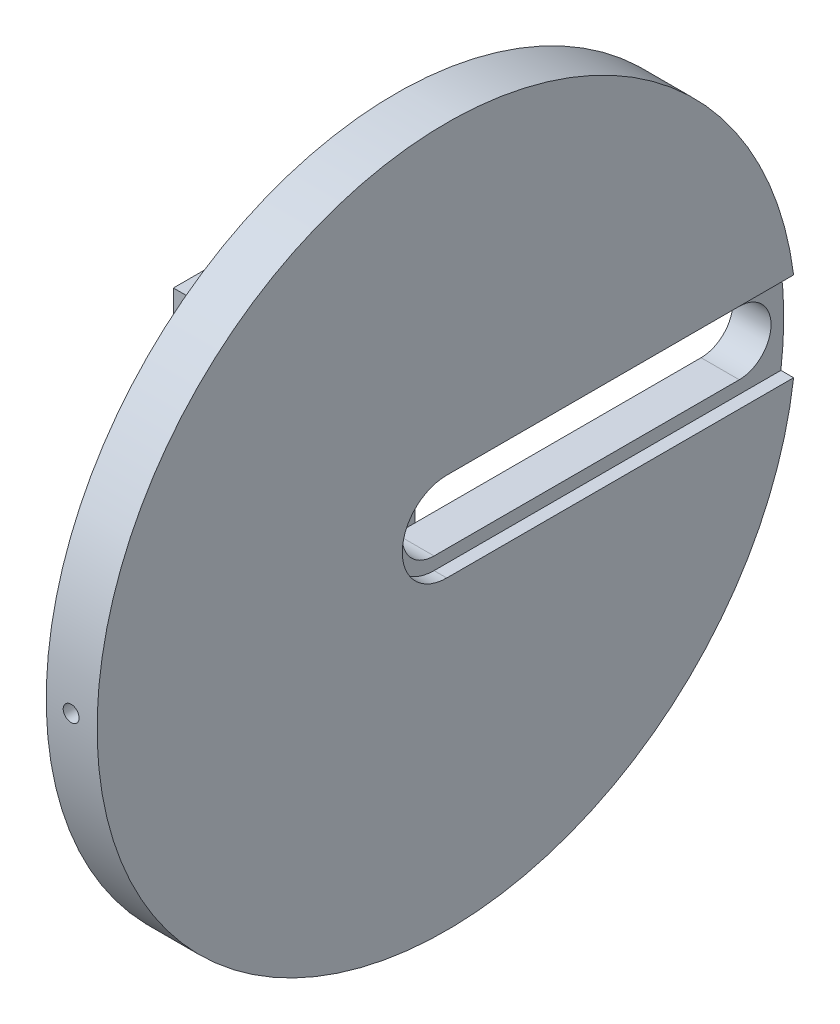
from build123d import *

# Parameters (mm, degrees)
SKETCH_1_R             = 7.5
EXTRUDE_1_DEPTH        = 10
SKETCH_5_W             = 30
SKETCH_5_H             = 52
EXTRUDE_2_DEPTH        = 8
SKETCH_6_W             = 30
SKETCH_6_H             = 8
EXTRUDE_3_DEPTH        = 12
SKETCH_7_R             = 55
EXTRUDE_4_DEPTH        = 8
CUT_EXTRUDE_4_REACH    = 40
CUT_EXTRUDE_6_DEPTH    = 2
CUT_EXTRUDE_7_REACH    = 40
SKETCH_12_R            = 9
HOLE_WIZARD_M3_1_D     = 2.5
HOLE_WIZARD_M3_1_DEPTH = 5
HOLE_WIZARD_M3_1_TIP   = 0.751075774


with BuildPart() as part:
    # 草图1 → 凸台-拉伸1 (new body)
    with BuildSketch(Plane(origin=(0, 0, 0), x_dir=(0, 0, -1), z_dir=(1, 0, 0))):
        Circle(SKETCH_1_R)
    extrude(amount=EXTRUDE_1_DEPTH)

    # 草图5 → 凸台-拉伸2 (add)
    with BuildSketch(Plane(origin=(10, 0, 0), x_dir=(0, 0, -1), z_dir=(1, 0, 0))):
        Rectangle(SKETCH_5_W, SKETCH_5_H)
    extrude(amount=EXTRUDE_2_DEPTH)

    # 草图6 → 凸台-拉伸3 (add)
    with BuildSketch(Plane(origin=(18, 0, 0), x_dir=(0, 0, -1), z_dir=(1, 0, 0))):
        with Locations((0, 22)):
            Rectangle(SKETCH_6_W, SKETCH_6_H)
        with Locations((0, -22)):
            Rectangle(SKETCH_6_W, SKETCH_6_H)
    extrude(amount=EXTRUDE_3_DEPTH)

    # 草图7 → 凸台-拉伸4 (add)
    with BuildSketch(Plane(origin=(30, 0, 0), x_dir=(0, 0, -1), z_dir=(1, 0, 0))):
        Circle(SKETCH_7_R)
    extrude(amount=EXTRUDE_4_DEPTH)

    # 草图8 → 切除-拉伸4 (cut, up to next)
    with BuildSketch(Plane(origin=(38, 0, 0), x_dir=(0, 0, -1), z_dir=(1, 0, 0)), mode=Mode.PRIVATE) as cut_extrude_4_sk1:
        with BuildLine():
            Line((0, 5), (48, 5))
            ThreePointArc((48, 5), (53, 0), (48, -5))
            Line((48, -5), (0, -5))
            ThreePointArc((0, -5), (-5, 0), (0, 5))
        make_face()
    cut_extrude_4_tool1 = extrude(cut_extrude_4_sk1.sketch, amount=-CUT_EXTRUDE_4_REACH, mode=Mode.PRIVATE) & part.part
    add(cut_extrude_4_tool1.solids().sort_by_distance((38, 0, -24))[0], mode=Mode.SUBTRACT)

    # 草图11 → 切除-拉伸6 (cut)
    with BuildSketch(Plane(origin=(38, 0, 0), x_dir=(0, 0, -1), z_dir=(1, 0, 0))):
        with BuildLine():
            Line((0, 7), (54.552726788, 7))
            ThreePointArc((54.552726788, 7), (55, 0), (54.552726788, -7))
            Line((54.552726788, -7), (0, -7))
            ThreePointArc((0, -7), (-7, 0), (0, 7))
        make_face()
    extrude(amount=-CUT_EXTRUDE_6_DEPTH, mode=Mode.SUBTRACT)

    # 草图12 → 切除-拉伸7 (cut, up to next)
    with BuildSketch(Plane.ZY, mode=Mode.PRIVATE) as cut_extrude_7_sk1:
        Circle(SKETCH_12_R)
    cut_extrude_7_tool1 = extrude(cut_extrude_7_sk1.sketch, amount=-CUT_EXTRUDE_7_REACH, mode=Mode.PRIVATE) & part.part
    add(cut_extrude_7_tool1.solids().sort_by_distance((0, 0, 0))[0], mode=Mode.SUBTRACT)

    # M3 螺纹孔1
    with Locations(Plane(origin=(33.918718573, 0, 55), x_dir=(1, 0, 0), z_dir=(0, 0, 1))):
        with Locations((0, 0)):
            Hole(HOLE_WIZARD_M3_1_D / 2, depth=HOLE_WIZARD_M3_1_DEPTH)
            with Locations((0, 0, -(HOLE_WIZARD_M3_1_DEPTH + HOLE_WIZARD_M3_1_TIP / 2))):  # 118° drill point
                Cone(0, HOLE_WIZARD_M3_1_D / 2, HOLE_WIZARD_M3_1_TIP, mode=Mode.SUBTRACT)


solid = part.part
